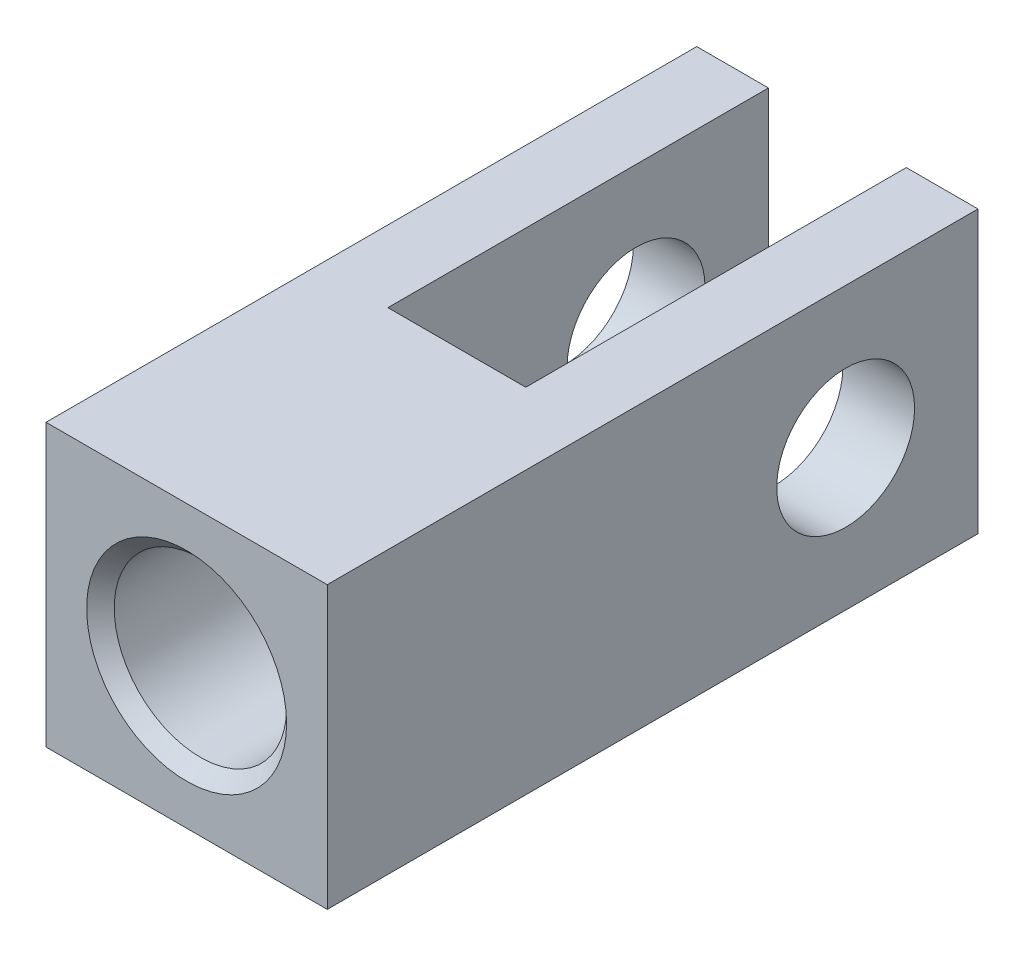
from build123d import *

# Parameters (mm, degrees)
SKETCH1_W                          = 12.954
SKETCH1_H                          = 29.972
EXTRUDE1_DEPTH                     = 6.477
SKETCH2_W                          = 6.35
SKETCH2_H                          = 17.526
EXTRUDE2_DEPTH                     = 13.954
SKETCH5_R                          = 3.175
EXTRUDE3_DEPTH                     = 13.954
F_5_16_24_TAPPED_HOLE1_D           = 7.9375
F_5_16_24_TAPPED_HOLE1_DEPTH       = 12.446
F_5_16_24_TAPPED_HOLE1_CSINK_D     = 9.2075
F_5_16_24_TAPPED_HOLE1_CSINK_ANGLE = 90


with BuildPart() as part:
    # Sketch1 → Extrude1 (new body, symmetric)
    with BuildSketch(Plane(origin=(0, 0, 0), x_dir=(1, 0, 0), z_dir=(0, 1, 0))):
        Rectangle(SKETCH1_W, SKETCH1_H)
    extrude(amount=EXTRUDE1_DEPTH, both=True)

    # Sketch2 → Extrude2 (cut, through all)
    with BuildSketch(Plane(origin=(0, 6.477, 0), x_dir=(1, 0, 0), z_dir=(0, 1, 0))):
        with Locations((0, 6.223)):
            Rectangle(SKETCH2_W, SKETCH2_H)
    extrude(amount=-EXTRUDE2_DEPTH, mode=Mode.SUBTRACT)

    # Sketch5 → Extrude3 (cut, through all)
    with BuildSketch(Plane(origin=(6.477, 0, 0), x_dir=(0, 0, -1), z_dir=(1, 0, 0))):
        with Locations((8.89, 0)):
            Circle(SKETCH5_R)
    extrude(amount=-EXTRUDE3_DEPTH, mode=Mode.SUBTRACT)

    # 5/16-24 Tapped Hole1
    with Locations(Plane.XY.offset(14.986)):
        with Locations((0, 0)):
            CounterSinkHole(F_5_16_24_TAPPED_HOLE1_D / 2, F_5_16_24_TAPPED_HOLE1_CSINK_D / 2, depth=F_5_16_24_TAPPED_HOLE1_DEPTH, counter_sink_angle=F_5_16_24_TAPPED_HOLE1_CSINK_ANGLE)


solid = part.part
